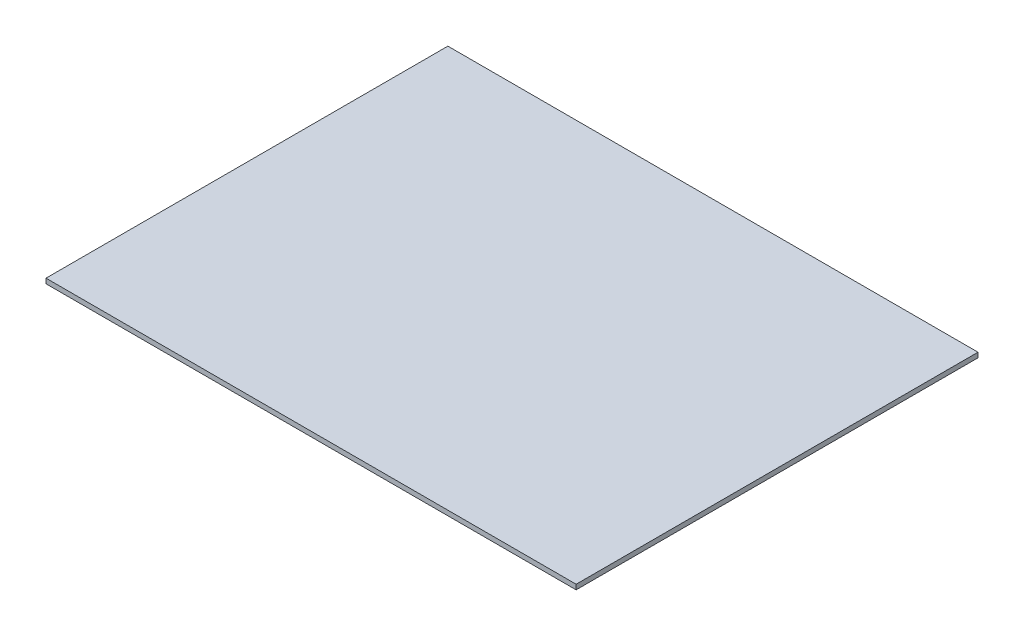
from build123d import *

# Parameters (mm, degrees)
SKETCH_1_W      = 434
SKETCH_1_H      = 329
EXTRUDE_1_DEPTH = 4


with BuildPart() as part:
    # Эскиз1 → Бобышка-Вытянуть1 (new body)
    with BuildSketch(Plane(origin=(0, 0, 0), x_dir=(1, 0, 0), z_dir=(0, 1, 0))):
        Rectangle(SKETCH_1_W, SKETCH_1_H)
    extrude(amount=EXTRUDE_1_DEPTH)


solid = part.part
